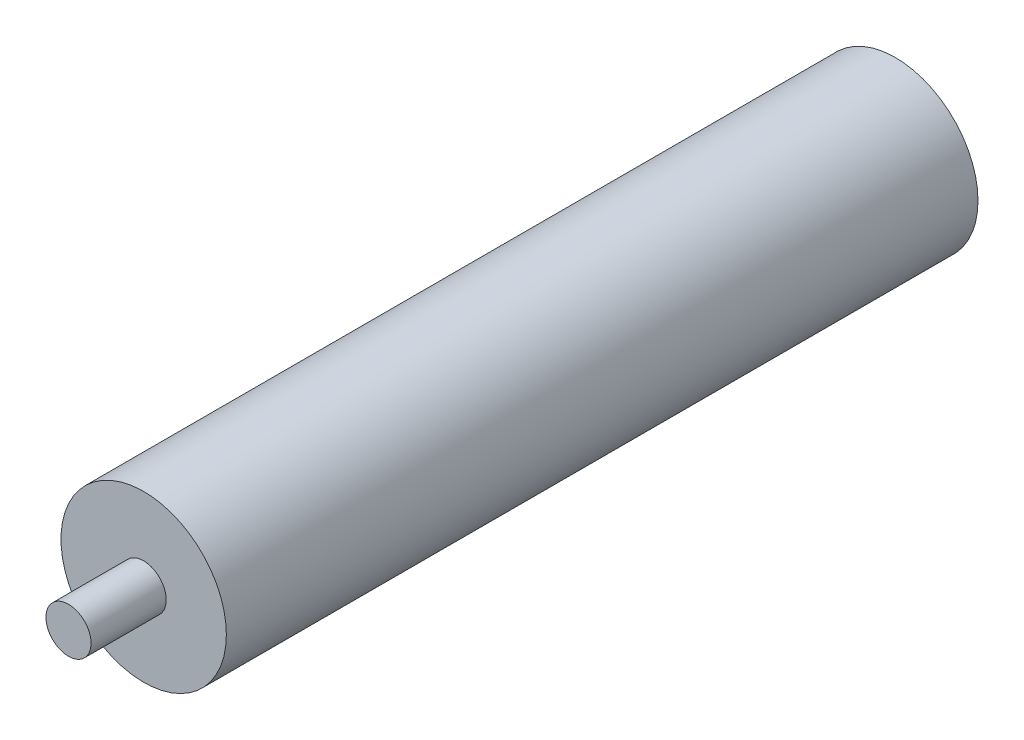
from build123d import *

# Parameters (mm, degrees)
SKETCH1_R           = 5.5
BOSS_EXTRUDE1_DEPTH = 50
SKETCH2_R           = 1.5
BOSS_EXTRUDE2_DEPTH = 5


with BuildPart() as part:
    # Sketch1 → Boss-Extrude1 (new body)
    with BuildSketch(Plane.XY):
        Circle(SKETCH1_R)
    extrude(amount=BOSS_EXTRUDE1_DEPTH)

    # Sketch2 → Boss-Extrude2 (add)
    with BuildSketch(Plane.XY.offset(50)):
        Circle(SKETCH2_R)
    extrude(amount=BOSS_EXTRUDE2_DEPTH)


solid = part.part
